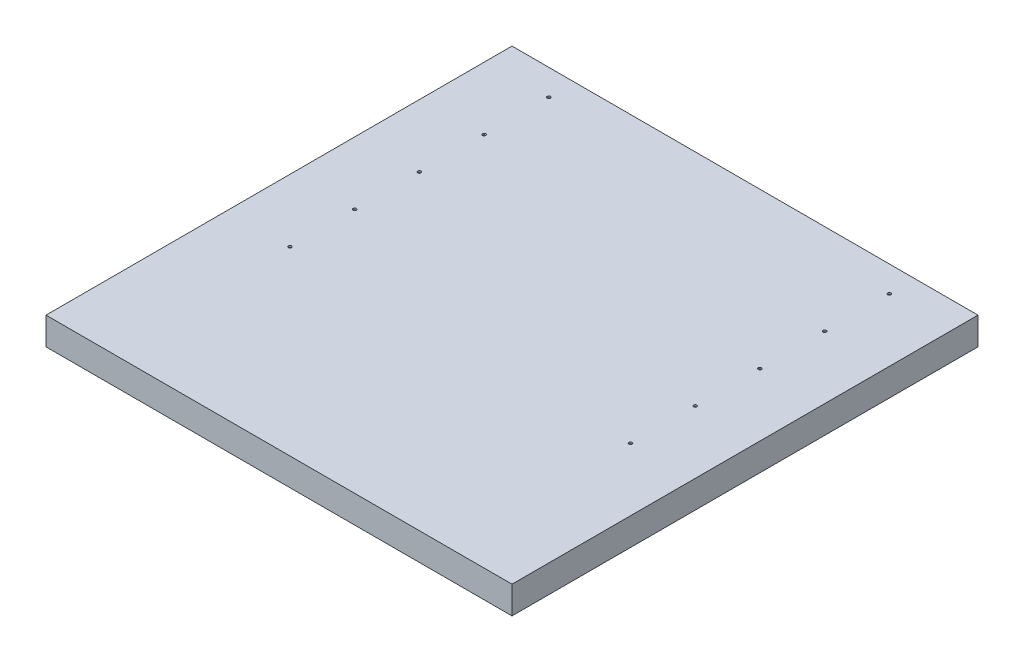
from build123d import *

# Parameters (mm, degrees)
SKETCH1_W           = 914.4
SKETCH1_H           = 914.4
SKETCH1_R           = 3.175
BOSS_EXTRUDE1_DEPTH = 3.175
SKETCH4_W           = 914.4
SKETCH4_H           = 914.4
SKETCH4_W_2         = 908.05
SKETCH4_H_2         = 908.05
BOSS_EXTRUDE2_DEPTH = 50.8


with BuildPart() as part:
    # Sketch1 → Boss-Extrude1 (new body)
    with BuildSketch(Plane(origin=(0, 0, 0), x_dir=(1, 0, 0), z_dir=(0, 1, 0))):
        Rectangle(SKETCH1_W, SKETCH1_H)
        with Locations((-334.137, 406.4)):
            Circle(SKETCH1_R, mode=Mode.SUBTRACT)
        with Locations((-334.137, 279.4)):
            Circle(SKETCH1_R, mode=Mode.SUBTRACT)
        with Locations((-334.137, 152.4)):
            Circle(SKETCH1_R, mode=Mode.SUBTRACT)
        with Locations((-334.137, 25.4)):
            Circle(SKETCH1_R, mode=Mode.SUBTRACT)
        with Locations((-334.137, -101.6)):
            Circle(SKETCH1_R, mode=Mode.SUBTRACT)
        with Locations((334.137, -101.6)):
            Circle(SKETCH1_R, mode=Mode.SUBTRACT)
        with Locations((334.137, 25.4)):
            Circle(SKETCH1_R, mode=Mode.SUBTRACT)
        with Locations((334.137, 152.4)):
            Circle(SKETCH1_R, mode=Mode.SUBTRACT)
        with Locations((334.137, 279.4)):
            Circle(SKETCH1_R, mode=Mode.SUBTRACT)
        with Locations((334.137, 406.4)):
            Circle(SKETCH1_R, mode=Mode.SUBTRACT)
    extrude(amount=BOSS_EXTRUDE1_DEPTH)

    # Sketch4 → Boss-Extrude2 (add)
    with BuildSketch(Plane.XZ):
        Rectangle(SKETCH4_W, SKETCH4_H)
        Rectangle(SKETCH4_W_2, SKETCH4_H_2, mode=Mode.SUBTRACT)
    extrude(amount=BOSS_EXTRUDE2_DEPTH)


solid = part.part
